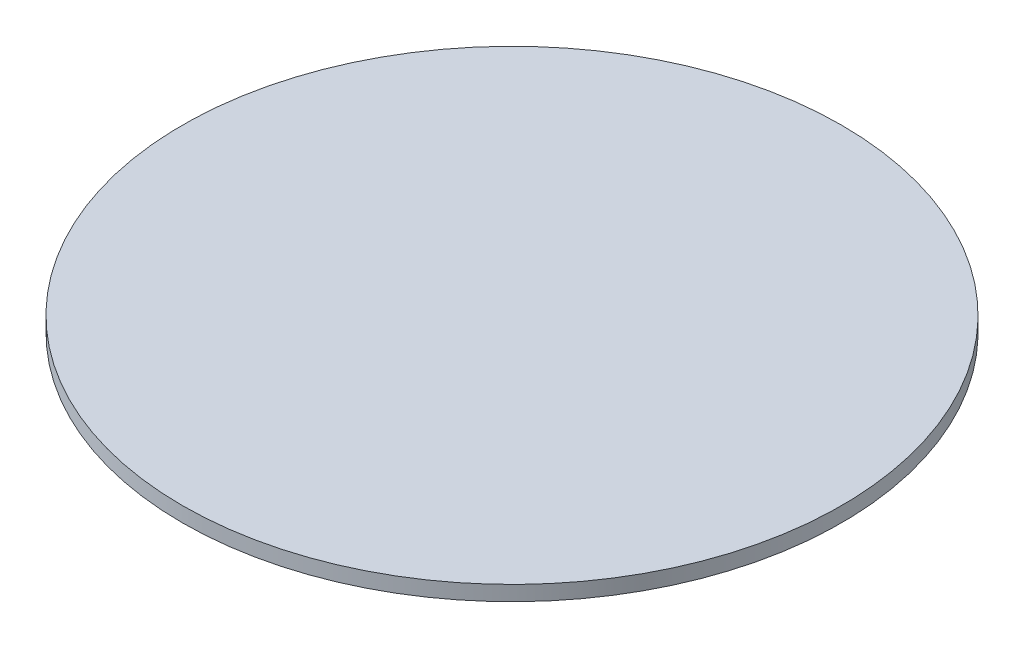
from build123d import *

# Parameters (mm, degrees)
ESQUISSE1_R        = 17.62
BOSS_EXTRU_1_DEPTH = 0.8


with BuildPart() as part:
    # Esquisse1 → Boss.-Extru.1 (new body)
    with BuildSketch(Plane(origin=(0, 0, 0), x_dir=(1, 0, 0), z_dir=(0, 1, 0))):
        Circle(ESQUISSE1_R)
    extrude(amount=BOSS_EXTRU_1_DEPTH)


solid = part.part
